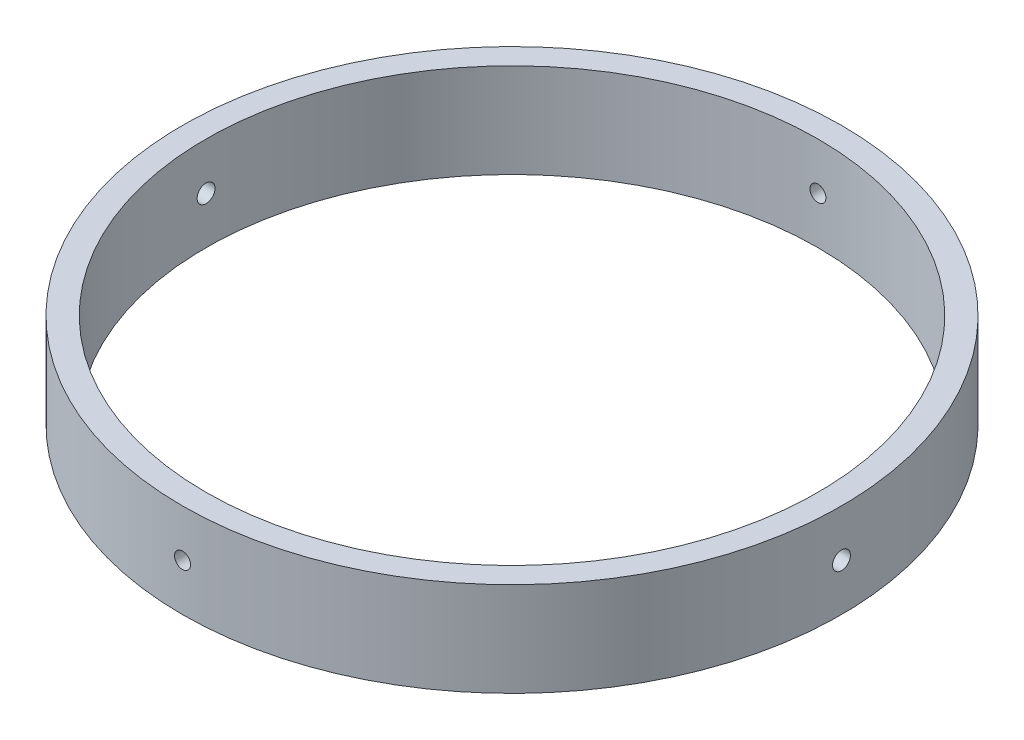
from build123d import *

# Parameters (mm, degrees)
SKETCH1_R               = 88.9
SKETCH1_R_2             = 82.55
BOSS_EXTRUDE1_DEPTH     = 25.4
SKETCH2_R               = 2.413
CUT_EXTRUDE1_DEPTH      = 89.9
CUT_EXTRUDE1_DEPTH_BACK = 89.9
SKETCH3_R               = 2.159
CUT_EXTRUDE2_DEPTH      = 89.9000001
CUT_EXTRUDE2_DEPTH_BACK = 89.9000001


with BuildPart() as part:
    # Sketch1 → Boss-Extrude1 (new body)
    with BuildSketch(Plane(origin=(0, 0, 0), x_dir=(1, 0, 0), z_dir=(0, 1, 0))):
        Circle(SKETCH1_R)
        Circle(SKETCH1_R_2, mode=Mode.SUBTRACT)
    extrude(amount=BOSS_EXTRUDE1_DEPTH)

    # Sketch2 → Cut-Extrude1 (cut, two sides)
    with BuildSketch(Plane(origin=(0, 0, 0), x_dir=(0, 0, -1), z_dir=(1, 0, 0))) as cut_extrude1_sk:
        with Locations((0, 12.7)):
            Circle(SKETCH2_R)
    extrude(amount=CUT_EXTRUDE1_DEPTH, mode=Mode.SUBTRACT)
    extrude(cut_extrude1_sk.sketch, amount=-CUT_EXTRUDE1_DEPTH_BACK, mode=Mode.SUBTRACT)

    # Sketch3 → Cut-Extrude2 (cut, two sides)
    with BuildSketch(Plane.XY) as cut_extrude2_sk:
        with Locations((0, 12.7)):
            Circle(SKETCH3_R)
    extrude(amount=CUT_EXTRUDE2_DEPTH, mode=Mode.SUBTRACT)
    extrude(cut_extrude2_sk.sketch, amount=-CUT_EXTRUDE2_DEPTH_BACK, mode=Mode.SUBTRACT)


solid = part.part
